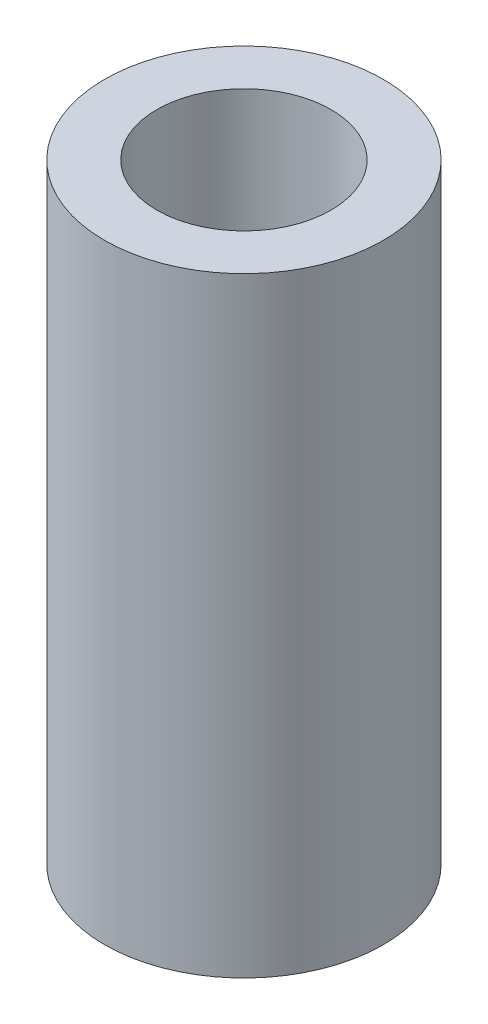
from build123d import *

# Parameters (mm, degrees)
SKETCH1_R           = 8
SKETCH1_R_2         = 5
BOSS_EXTRUDE1_DEPTH = 35


with BuildPart() as part:
    # Sketch1 → Boss-Extrude1 (new body)
    with BuildSketch(Plane(origin=(0, 0, 0), x_dir=(1, 0, 0), z_dir=(0, 1, 0))):
        Circle(SKETCH1_R)
        Circle(SKETCH1_R_2, mode=Mode.SUBTRACT)
    extrude(amount=BOSS_EXTRUDE1_DEPTH)


solid = part.part
